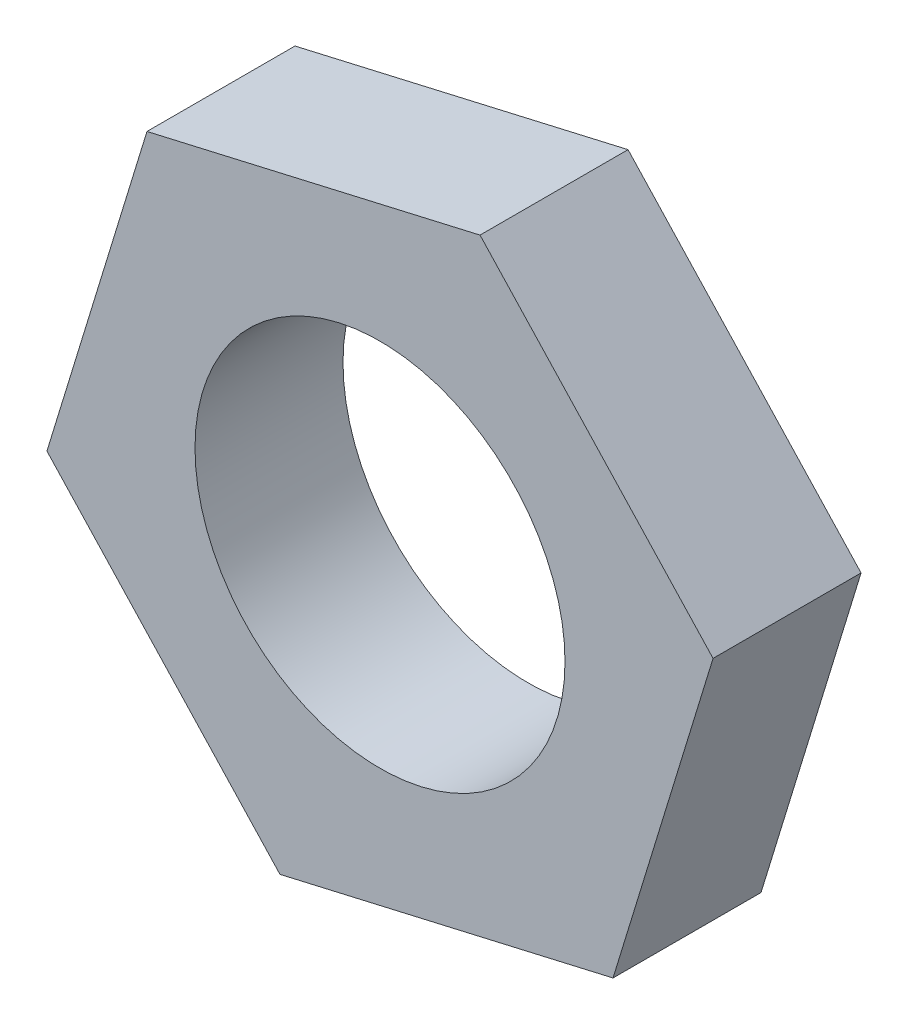
from build123d import *

# Parameters (mm, degrees)
BOSS_EXTRU_1_DEPTH      = 20
ESQUISSE2_R             = 25
ENL_V_MAT_EXTRU_1_DEPTH = 20


with BuildPart() as part:
    # Esquisse1 → Boss.-Extru.1 (new body)
    with BuildSketch(Plane.XY):
        Polygon((-31.488893583, 33.790278399), (-45.007686286, -10.37504258), (-13.518792703, -44.165320979), (31.488893583, -33.790278399), (45.007686286, 10.37504258), (13.518792703, 44.165320979), align=None)
    extrude(amount=BOSS_EXTRU_1_DEPTH)

    # Esquisse2 → Enlèv. mat.-Extru.1 (cut)
    with BuildSketch(Plane.XY.offset(20)):
        Circle(ESQUISSE2_R)
    extrude(amount=-ENL_V_MAT_EXTRU_1_DEPTH, mode=Mode.SUBTRACT)


solid = part.part
